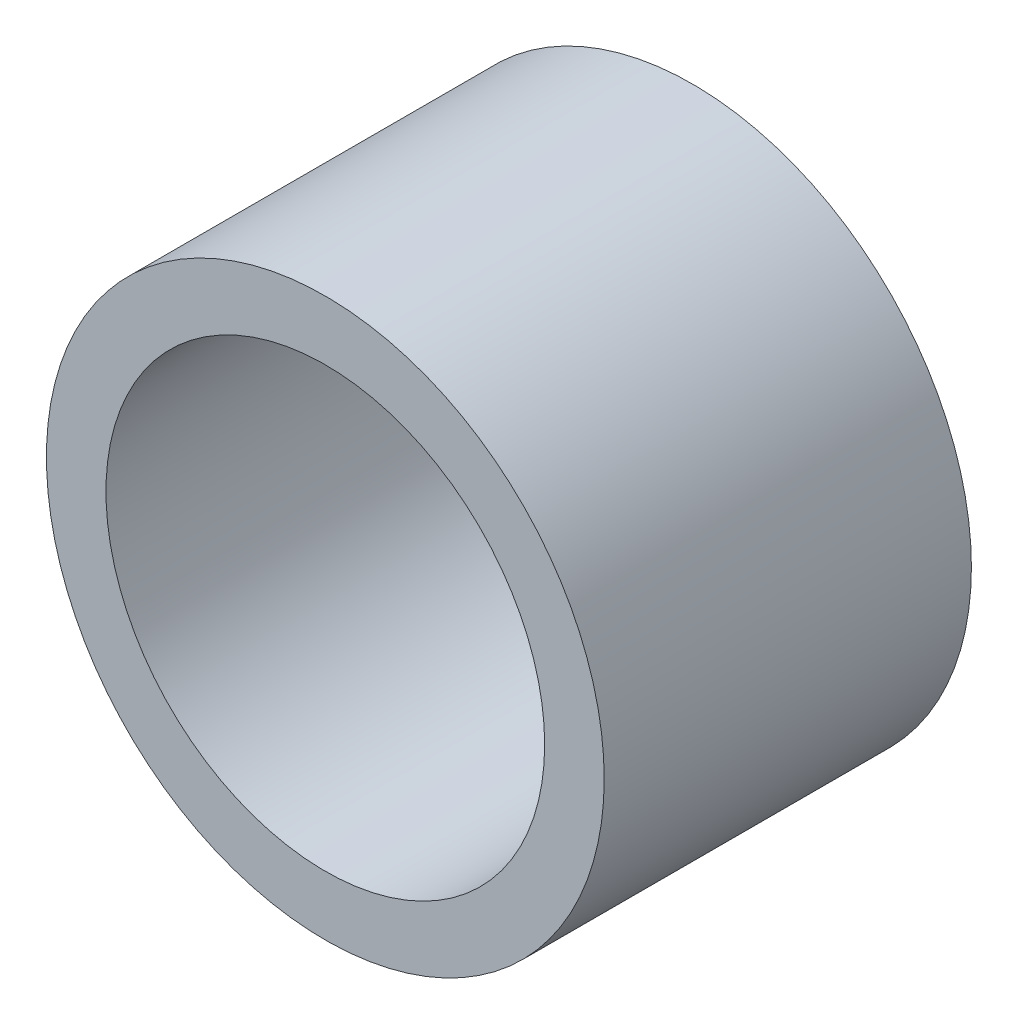
from build123d import *

# Parameters (mm, degrees)
SKETCH1_R           = 38.584371226
SKETCH1_R_2         = 30.347159063
BOSS_EXTRUDE1_DEPTH = 50.8


with BuildPart() as part:
    # Sketch1 → Boss-Extrude1 (new body)
    with BuildSketch(Plane.XY):
        with Locations((0, 6.122935479)):
            Circle(SKETCH1_R)
        with Locations((0, 6.122935479)):
            Circle(SKETCH1_R_2, mode=Mode.SUBTRACT)
    extrude(amount=BOSS_EXTRUDE1_DEPTH)


solid = part.part
